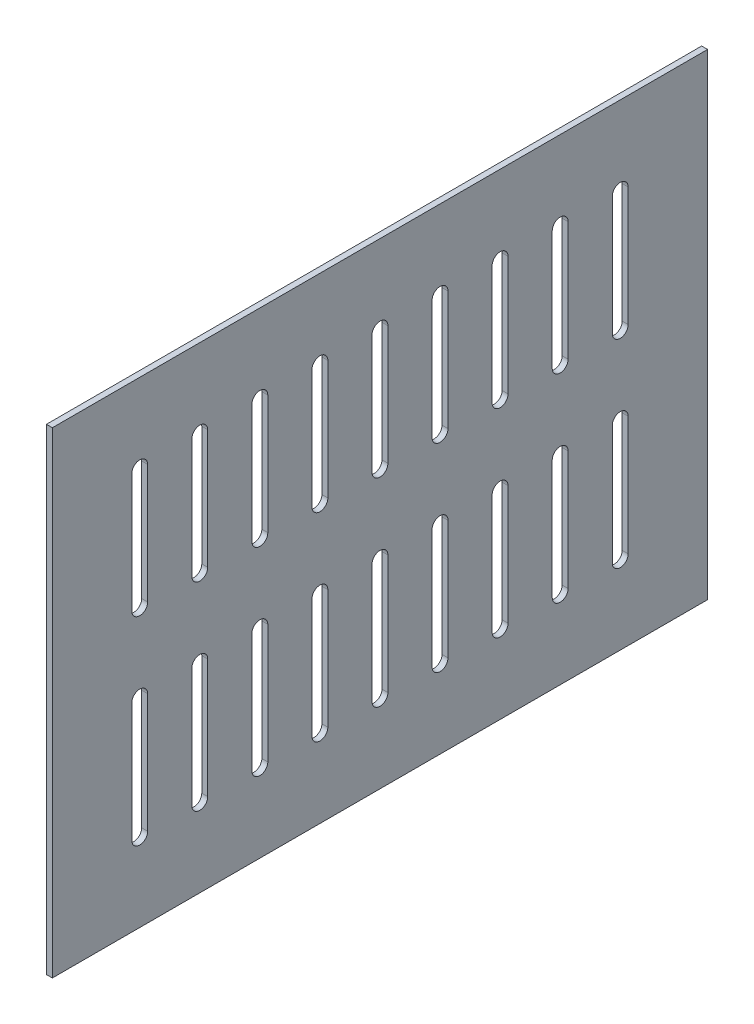
from build123d import *

# Parameters (mm, degrees)
IZIM1_W                     = 330
IZIM1_H                     = 240
Y_KSEKLIK_EKSTR_ZYON1_DEPTH = 3


with BuildPart() as part:
    # Çizim1 → Yükseklik-Ekstrüzyon1 (new body)
    with BuildSketch(Plane(origin=(0, 0, 0), x_dir=(0, 0, -1), z_dir=(1, 0, 0))):
        with Locations((165, -120)):
            Rectangle(IZIM1_W, IZIM1_H)
        with BuildLine():
            Line((48, -40), (48, -100))
            ThreePointArc((48, -100), (44, -104), (40, -100))
            Line((40, -100), (40, -40))
            ThreePointArc((40, -40), (44, -36), (48, -40))
        make_face(mode=Mode.SUBTRACT)
        with BuildLine():
            Line((78.25, -40), (78.25, -100))
            ThreePointArc((78.25, -100), (74.25, -104), (70.25, -100))
            Line((70.25, -100), (70.25, -40))
            ThreePointArc((70.25, -40), (74.25, -36), (78.25, -40))
        make_face(mode=Mode.SUBTRACT)
        with BuildLine():
            Line((108.5, -40), (108.5, -100))
            ThreePointArc((108.5, -100), (104.5, -104), (100.5, -100))
            Line((100.5, -100), (100.5, -40))
            ThreePointArc((100.5, -40), (104.5, -36), (108.5, -40))
        make_face(mode=Mode.SUBTRACT)
        with BuildLine():
            Line((138.75, -40), (138.75, -100))
            ThreePointArc((138.75, -100), (134.75, -104), (130.75, -100))
            Line((130.75, -100), (130.75, -40))
            ThreePointArc((130.75, -40), (134.75, -36), (138.75, -40))
        make_face(mode=Mode.SUBTRACT)
        with BuildLine():
            Line((169, -40), (169, -100))
            ThreePointArc((169, -100), (165, -104), (161, -100))
            Line((161, -100), (161, -40))
            ThreePointArc((161, -40), (165, -36), (169, -40))
        make_face(mode=Mode.SUBTRACT)
        with BuildLine():
            Line((199.25, -40), (199.25, -100))
            ThreePointArc((199.25, -100), (195.25, -104), (191.25, -100))
            Line((191.25, -100), (191.25, -40))
            ThreePointArc((191.25, -40), (195.25, -36), (199.25, -40))
        make_face(mode=Mode.SUBTRACT)
        with BuildLine():
            Line((229.5, -40), (229.5, -100))
            ThreePointArc((229.5, -100), (225.5, -104), (221.5, -100))
            Line((221.5, -100), (221.5, -40))
            ThreePointArc((221.5, -40), (225.5, -36), (229.5, -40))
        make_face(mode=Mode.SUBTRACT)
        with BuildLine():
            Line((259.75, -40), (259.75, -100))
            ThreePointArc((259.75, -100), (255.75, -104), (251.75, -100))
            Line((251.75, -100), (251.75, -40))
            ThreePointArc((251.75, -40), (255.75, -36), (259.75, -40))
        make_face(mode=Mode.SUBTRACT)
        with BuildLine():
            Line((290, -40), (290, -100))
            ThreePointArc((290, -100), (286, -104), (282, -100))
            Line((282, -100), (282, -40))
            ThreePointArc((282, -40), (286, -36), (290, -40))
        make_face(mode=Mode.SUBTRACT)
        with BuildLine():
            Line((78.25, -140), (78.25, -200))
            ThreePointArc((78.25, -200), (74.25, -204), (70.25, -200))
            Line((70.25, -200), (70.25, -140))
            ThreePointArc((70.25, -140), (74.25, -136), (78.25, -140))
        make_face(mode=Mode.SUBTRACT)
        with BuildLine():
            Line((108.5, -140), (108.5, -200))
            ThreePointArc((108.5, -200), (104.5, -204), (100.5, -200))
            Line((100.5, -200), (100.5, -140))
            ThreePointArc((100.5, -140), (104.5, -136), (108.5, -140))
        make_face(mode=Mode.SUBTRACT)
        with BuildLine():
            Line((138.75, -140), (138.75, -200))
            ThreePointArc((138.75, -200), (134.75, -204), (130.75, -200))
            Line((130.75, -200), (130.75, -140))
            ThreePointArc((130.75, -140), (134.75, -136), (138.75, -140))
        make_face(mode=Mode.SUBTRACT)
        with BuildLine():
            Line((169, -140), (169, -200))
            ThreePointArc((169, -200), (165, -204), (161, -200))
            Line((161, -200), (161, -140))
            ThreePointArc((161, -140), (165, -136), (169, -140))
        make_face(mode=Mode.SUBTRACT)
        with BuildLine():
            Line((199.25, -140), (199.25, -200))
            ThreePointArc((199.25, -200), (195.25, -204), (191.25, -200))
            Line((191.25, -200), (191.25, -140))
            ThreePointArc((191.25, -140), (195.25, -136), (199.25, -140))
        make_face(mode=Mode.SUBTRACT)
        with BuildLine():
            Line((229.5, -140), (229.5, -200))
            ThreePointArc((229.5, -200), (225.5, -204), (221.5, -200))
            Line((221.5, -200), (221.5, -140))
            ThreePointArc((221.5, -140), (225.5, -136), (229.5, -140))
        make_face(mode=Mode.SUBTRACT)
        with BuildLine():
            Line((259.75, -140), (259.75, -200))
            ThreePointArc((259.75, -200), (255.75, -204), (251.75, -200))
            Line((251.75, -200), (251.75, -140))
            ThreePointArc((251.75, -140), (255.75, -136), (259.75, -140))
        make_face(mode=Mode.SUBTRACT)
        with BuildLine():
            Line((290, -140), (290, -200))
            ThreePointArc((290, -200), (286, -204), (282, -200))
            Line((282, -200), (282, -140))
            ThreePointArc((282, -140), (286, -136), (290, -140))
        make_face(mode=Mode.SUBTRACT)
        with BuildLine():
            Line((48, -140), (48, -200))
            ThreePointArc((48, -200), (44, -204), (40, -200))
            Line((40, -200), (40, -140))
            ThreePointArc((40, -140), (44, -136), (48, -140))
        make_face(mode=Mode.SUBTRACT)
    extrude(amount=Y_KSEKLIK_EKSTR_ZYON1_DEPTH)


solid = part.part
